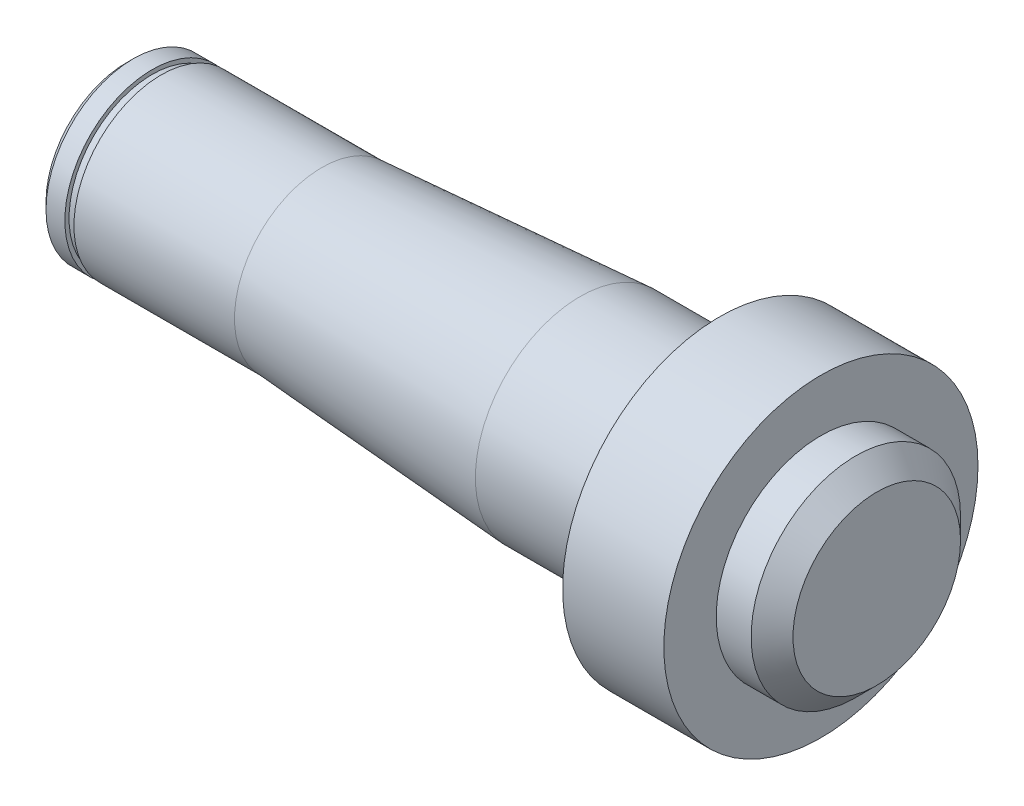
from build123d import *

# Parameters (mm, degrees)
CHANFREIN1_SIZE = 1
CHANFREIN2_SIZE = 3


with BuildPart() as part:
    # Esquisse1 → Révolution1 (revolve)
    with BuildSketch(Plane.XY, mode=Mode.PRIVATE) as r_volution1_sk:
        Polygon((0, 0), (0, 15), (-8, 15), (-8, 22.5), (-22.5, 22.5), (-22.5, 15), (-42.5, 15), (-79.5, 12.5), (-102.5, 12.5), (-102.5, 11.9), (-103.8, 11.9), (-103.8, 12.5), (-107.5, 12.5), (-107.5, 0), align=None)
    revolve(r_volution1_sk.sketch.rotate(Axis((0, 0, 0), (-1, 0, 0)), 90), axis=Axis((0, 0, 0), (-1, 0, 0)))  # turned: the seam where the file's is

    # Chanfrein1
    chanfrein1_edges = [part.edges().sort_by_distance(p)[0] for p in [
        (-107.5, 0, 12.5),
    ]]
    chamfer(chanfrein1_edges, length=CHANFREIN1_SIZE)

    # Chanfrein2
    chanfrein2_edges = [part.edges().sort_by_distance(p)[0] for p in [
        (0, 0, 15),
    ]]
    chamfer(chanfrein2_edges, length=CHANFREIN2_SIZE)


solid = part.part
